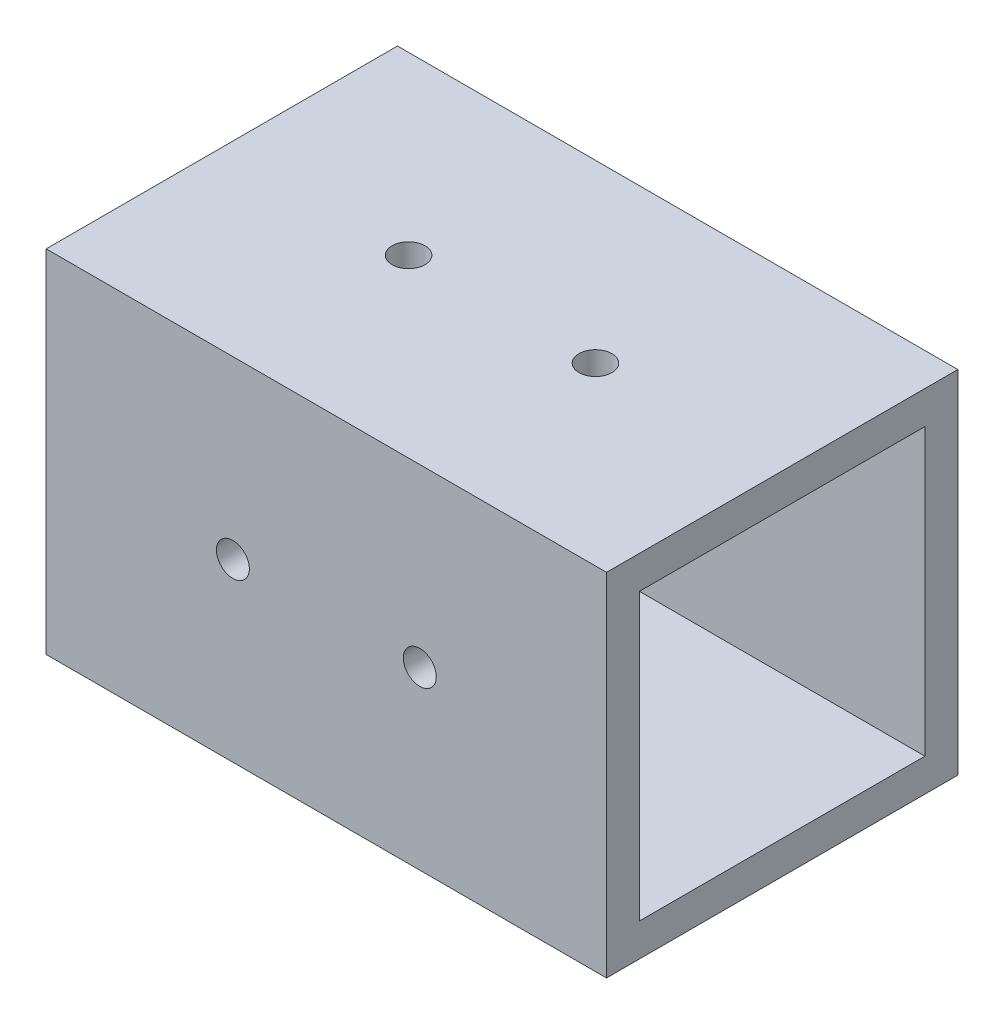
from build123d import *

# Parameters (mm, degrees)
SKETCH1_W           = 50.8
SKETCH1_H           = 50.8
SKETCH1_W_2         = 41.275
SKETCH1_H_2         = 41.275
BOSS_EXTRUDE1_DEPTH = 81.025
SKETCH2_R           = 2.38125
CUT_EXTRUDE1_DEPTH  = 50.8
SKETCH3_R           = 2.38125
CUT_EXTRUDE2_DEPTH  = 52.324


with BuildPart() as part:
    # Sketch1 → Boss-Extrude1 (new body)
    with BuildSketch(Plane(origin=(0, 0, 0), x_dir=(0, 0, -1), z_dir=(1, 0, 0))):
        with Locations((-25.4, 25.4)):
            Rectangle(SKETCH1_W, SKETCH1_H)
        with Locations((-25.4, 25.4)):
            Rectangle(SKETCH1_W_2, SKETCH1_H_2, mode=Mode.SUBTRACT)
    extrude(amount=BOSS_EXTRUDE1_DEPTH)

    # Sketch2 → Cut-Extrude1 (cut)
    with BuildSketch(Plane.XY.offset(50.8)):
        with Locations((27, 25.4)):
            Circle(SKETCH2_R)
        with Locations((54.025, 25.4)):
            Circle(SKETCH2_R)
    extrude(amount=-CUT_EXTRUDE1_DEPTH, mode=Mode.SUBTRACT)

    # Sketch3 → Cut-Extrude2 (cut)
    with BuildSketch(Plane.XZ):
        with Locations((27, 25.4)):
            Circle(SKETCH3_R)
        with Locations((54.025, 25.4)):
            Circle(SKETCH3_R)
    extrude(amount=-CUT_EXTRUDE2_DEPTH, mode=Mode.SUBTRACT)


solid = part.part
